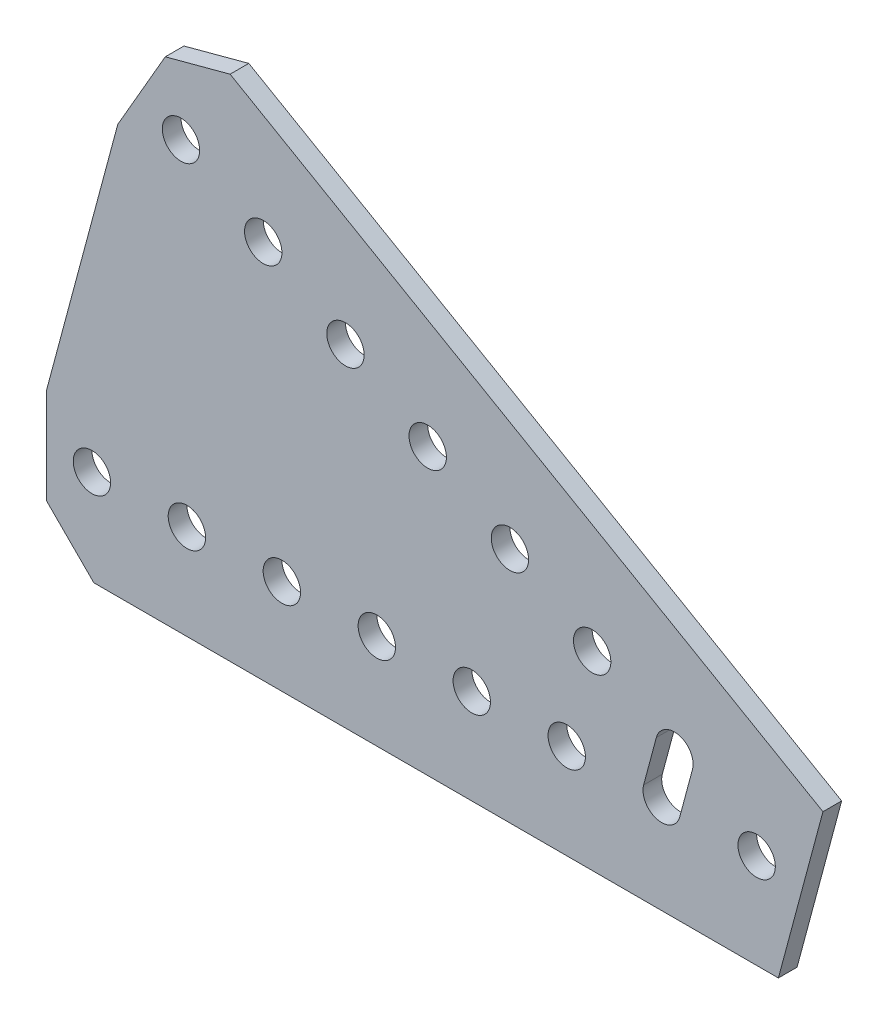
from build123d import *

# Parameters (mm, degrees)
SKETCH1_R           = 2.5
BOSS_EXTRUDE1_DEPTH = 2.5


with BuildPart() as part:
    # Sketch1 → Boss-Extrude1 (new body)
    with BuildSketch(Plane(origin=(0, 0, -1.25), x_dir=(-1, 0, 0), z_dir=(0, 0, -1))):
        Polygon((-2.908088852, -12.7), (88.646, -12.7), (94.996, -6.35), (94.996, 6.35), (85.443949258, 41.998738686), (79.093949258, 52.997261314), (70.419687944, 55.321522628), (-8.868478822, 9.544478202), align=None)
        with Locations((25.4, 0)):
            Circle(SKETCH1_R, mode=Mode.SUBTRACT)
        with Locations((38.1, 0)):
            Circle(SKETCH1_R, mode=Mode.SUBTRACT)
        with Locations((50.8, 0)):
            Circle(SKETCH1_R, mode=Mode.SUBTRACT)
        with Locations((63.5, 0)):
            Circle(SKETCH1_R, mode=Mode.SUBTRACT)
        Circle(SKETCH1_R, mode=Mode.SUBTRACT)
        with Locations((88.9, 0)):
            Circle(SKETCH1_R, mode=Mode.SUBTRACT)
        with Locations((76.2, 0)):
            Circle(SKETCH1_R, mode=Mode.SUBTRACT)
        with Locations((76.989658396, 44.45)):
            Circle(SKETCH1_R, mode=Mode.SUBTRACT)
        with Locations((65.991135768, 38.1)):
            Circle(SKETCH1_R, mode=Mode.SUBTRACT)
        with Locations((54.99261314, 31.75)):
            Circle(SKETCH1_R, mode=Mode.SUBTRACT)
        with Locations((43.994090512, 25.4)):
            Circle(SKETCH1_R, mode=Mode.SUBTRACT)
        with Locations((32.995567884, 19.05)):
            Circle(SKETCH1_R, mode=Mode.SUBTRACT)
        with Locations((21.997045256, 12.7)):
            Circle(SKETCH1_R, mode=Mode.SUBTRACT)
        with BuildLine():
            Line((10.285185434, -0.647047613), (8.583708062, 5.702952387))
            ThreePointArc((8.583708062, 5.702952387), (10.351475015, 8.764814566), (13.413337194, 6.997047613))
            Line((13.413337194, 6.997047613), (15.114814566, 0.647047613))
            ThreePointArc((15.114814566, 0.647047613), (13.347047613, -2.414814566), (10.285185434, -0.647047613))
        make_face(mode=Mode.SUBTRACT)
    extrude(amount=-BOSS_EXTRUDE1_DEPTH)


solid = part.part
